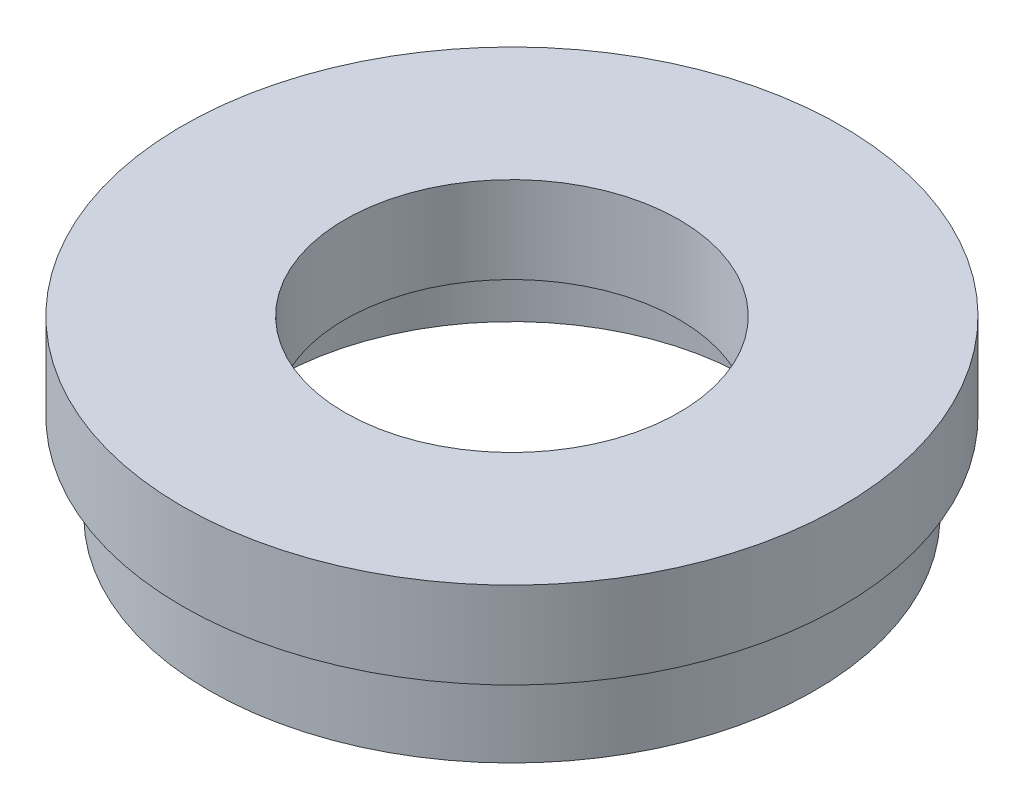
from build123d import *


with BuildPart() as part:
    # 草图1 → 旋转1 (revolve)
    with BuildSketch(Plane.XY, mode=Mode.PRIVATE) as revolve_1_sk:
        Polygon((17.5, 0), (13.75, 0), (13.75, 4), (14.35, 4), (14.35, 5), (9.66, 5), (9.66, 10), (19.05, 10), (19.05, 5), (17, 5), (17, 4), (17.5, 4), align=None)
    revolve(revolve_1_sk.sketch.rotate(Axis((0, 13.744680851, 0), (0, -1, 0)), 90), axis=Axis((0, 13.744680851, 0), (0, -1, 0)))  # turned: the seam where the file's is


solid = part.part
